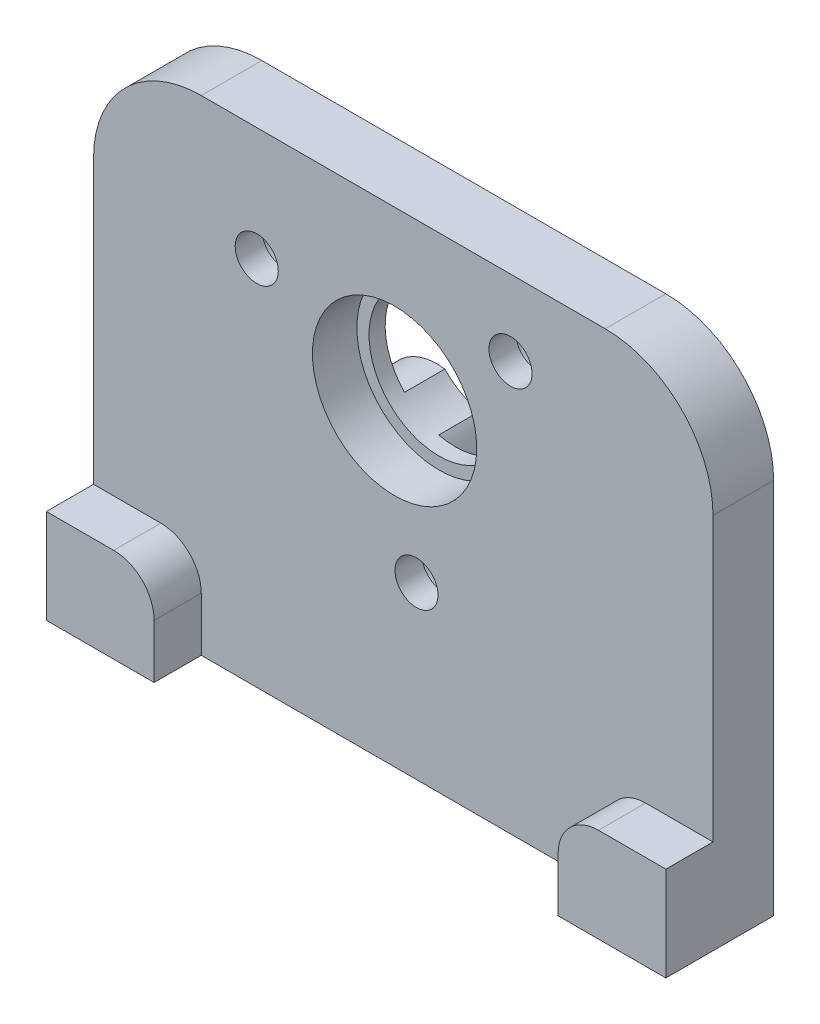
from build123d import *

# Parameters (mm, degrees)
SKETCH1_W                                        = 46
SKETCH1_H                                        = 36
BOSS_EXTRUDE1_DEPTH                              = 4.5
SKETCH2_W                                        = 8
SKETCH2_H                                        = 7
BOSS_EXTRUDE2_DEPTH                              = 3.5
SKETCH3_W                                        = 7.999999995
SKETCH3_H                                        = 7
BOSS_EXTRUDE3_DEPTH                              = 3.5
SKETCH4_W                                        = 4
SKETCH4_H                                        = 3
F_2_05_2_05_DIAMETER_HOLE1_D                     = 2.05
F_2_05_2_05_DIAMETER_HOLE1_DEPTH                 = 8
F_2_05_2_05_DIAMETER_HOLE1_TIP                   = 0.615882135
F_2_5_2_5_DIAMETER_HOLE1_D                       = 2.5
F_2_5_2_5_DIAMETER_HOLE1_DEPTH                   = 6
F_2_5_2_5_DIAMETER_HOLE1_TIP                     = 0.751075774
CBORE_FOR_M3_HEX_HEAD_MACHINE_SCREW1_D           = 3.2
CBORE_FOR_M3_HEX_HEAD_MACHINE_SCREW1_DEPTH       = 8.000025
CBORE_FOR_M3_HEX_HEAD_MACHINE_SCREW1_CBORE_D     = 5.4
CBORE_FOR_M3_HEX_HEAD_MACHINE_SCREW1_CBORE_DEPTH = 2.5
HOLE1_D                                          = 10.4
HOLE1_CBORE_D                                    = 12.2
HOLE1_CBORE_DEPTH                                = 3.3
F_4_2_4_2_DIAMETER_HOLE1_D                       = 4.2
F_4_2_4_2_DIAMETER_HOLE1_DEPTH                   = 7
FILLET1_R                                        = 3
FILLET2_R                                        = 8


with BuildPart() as part:
    # Sketch1 → Boss-Extrude1 (new body)
    with BuildSketch(Plane.XY.offset(4.5)):
        Rectangle(SKETCH1_W, SKETCH1_H)
    extrude(amount=-BOSS_EXTRUDE1_DEPTH)

    # Sketch2 → Boss-Extrude2 (add)
    with BuildSketch(Plane.XY.offset(4.5)):
        with Locations((-19, -14.5)):
            Rectangle(SKETCH2_W, SKETCH2_H)
    extrude(amount=BOSS_EXTRUDE2_DEPTH)

    # Sketch3 → Boss-Extrude3 (add)
    with BuildSketch(Plane.XY.offset(4.5)):
        with Locations((19.000000003, -14.5)):
            Rectangle(SKETCH3_W, SKETCH3_H)
    extrude(amount=BOSS_EXTRUDE3_DEPTH)

    # Sketch4 → Revolve1 (revolve)
    with BuildSketch(Plane(origin=(0, -2, 0), x_dir=(1, 0, 0), z_dir=(0, 1, 0))):
        with Locations((-3, 1.5)):
            Rectangle(SKETCH4_W, SKETCH4_H)
    revolve(axis=Axis((-5, -2, -3), (0, 0, 1)))

    # Ø2.05 (2.05) Diameter Hole1
    with Locations(Plane(origin=(0, -18, 0), x_dir=(-1, 0, 0), z_dir=(0, -1, 0))):
        with Locations((0, -2.25)):
            Hole(F_2_05_2_05_DIAMETER_HOLE1_D / 2, depth=F_2_05_2_05_DIAMETER_HOLE1_DEPTH)
            with Locations((0, 0, -(F_2_05_2_05_DIAMETER_HOLE1_DEPTH + F_2_05_2_05_DIAMETER_HOLE1_TIP / 2))):  # 118° drill point
                Cone(0, F_2_05_2_05_DIAMETER_HOLE1_D / 2, F_2_05_2_05_DIAMETER_HOLE1_TIP, mode=Mode.SUBTRACT)

    # Ø2.5 (2.5) Diameter Hole1
    with Locations(Plane(origin=(0, -18, 0), x_dir=(-1, 0, 0), z_dir=(0, -1, 0))):
        with Locations((19, -4), (-19, -4)):
            Hole(F_2_5_2_5_DIAMETER_HOLE1_D / 2, depth=F_2_5_2_5_DIAMETER_HOLE1_DEPTH)
            with Locations((0, 0, -(F_2_5_2_5_DIAMETER_HOLE1_DEPTH + F_2_5_2_5_DIAMETER_HOLE1_TIP / 2))):  # 118° drill point
                Cone(0, F_2_5_2_5_DIAMETER_HOLE1_D / 2, F_2_5_2_5_DIAMETER_HOLE1_TIP, mode=Mode.SUBTRACT)

    # CBORE for M3 Hex Head Machine Screw1
    with Locations(Plane(origin=(0, 0, 0), x_dir=(-1, 0, 0), z_dir=(0, 0, -1))):
        with Locations((-7.962908944, 12.389389916), (10.88037403, 9.573242407), (-0.980122741, -5.337445584)):
            CounterBoreHole(CBORE_FOR_M3_HEX_HEAD_MACHINE_SCREW1_D / 2, CBORE_FOR_M3_HEX_HEAD_MACHINE_SCREW1_CBORE_D / 2, CBORE_FOR_M3_HEX_HEAD_MACHINE_SCREW1_CBORE_DEPTH, depth=CBORE_FOR_M3_HEX_HEAD_MACHINE_SCREW1_DEPTH)

    # Hole1 (through all)
    with Locations(Plane.XY.offset(4.5)):
        with Locations((-0.645780782, 5.541728913)):
            CounterBoreHole(HOLE1_D / 2, HOLE1_CBORE_D / 2, HOLE1_CBORE_DEPTH)

    # Ø4.2 (4.2) Diameter Hole1
    with Locations(Plane(origin=(0, 0, -3), x_dir=(-1, 0, 0), z_dir=(0, 0, -1))):
        with Locations((5, -2)):
            Hole(F_4_2_4_2_DIAMETER_HOLE1_D / 2, depth=F_4_2_4_2_DIAMETER_HOLE1_DEPTH)

    # Fillet1
    fillet1_edges = [part.edges().sort_by_distance(p)[0] for p in [
        (-15, -11, 6.25),
        (15.000000005, -11, 6.25),
    ]]
    fillet(fillet1_edges, radius=FILLET1_R)

    # Fillet2
    fillet2_edges = [part.edges().sort_by_distance(p)[0] for p in [
        (23, 18, 2.25),
        (-23, 18, 2.25),
    ]]
    fillet(fillet2_edges, radius=FILLET2_R)


solid = part.part
